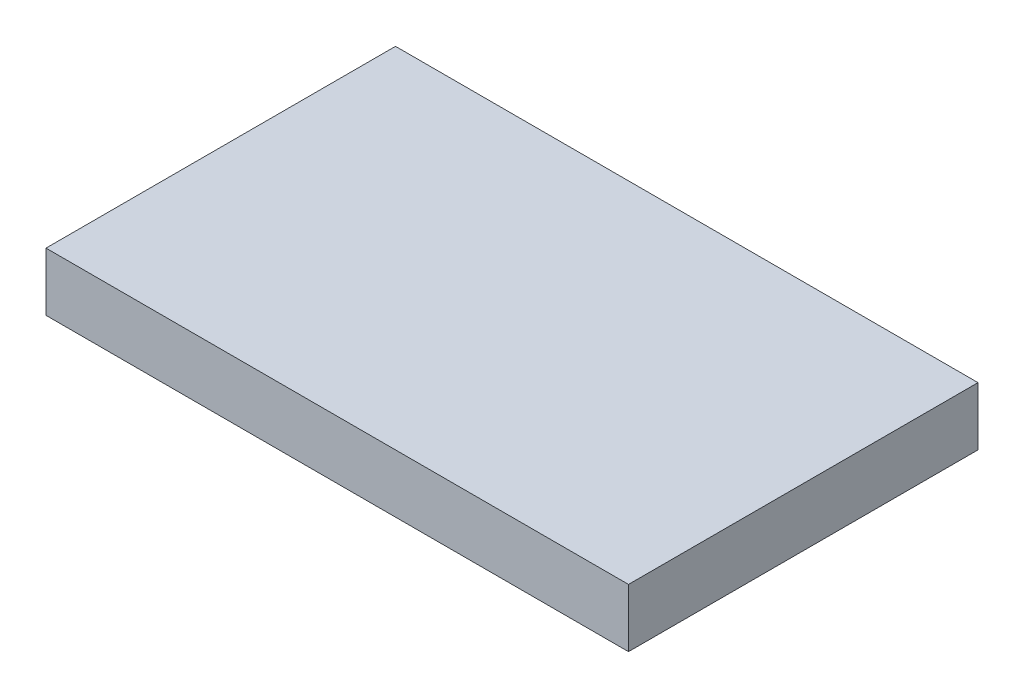
from build123d import *

# Parameters (mm, degrees)
SKETCH1_W           = 127
SKETCH1_H           = 76.2
BOSS_EXTRUDE1_DEPTH = 12.7


with BuildPart() as part:
    # Sketch1 → Boss-Extrude1 (new body)
    with BuildSketch(Plane(origin=(0, 0, 0), x_dir=(1, 0, 0), z_dir=(0, 1, 0))):
        with Locations((63.5, 38.1)):
            Rectangle(SKETCH1_W, SKETCH1_H)
    extrude(amount=BOSS_EXTRUDE1_DEPTH)


solid = part.part
